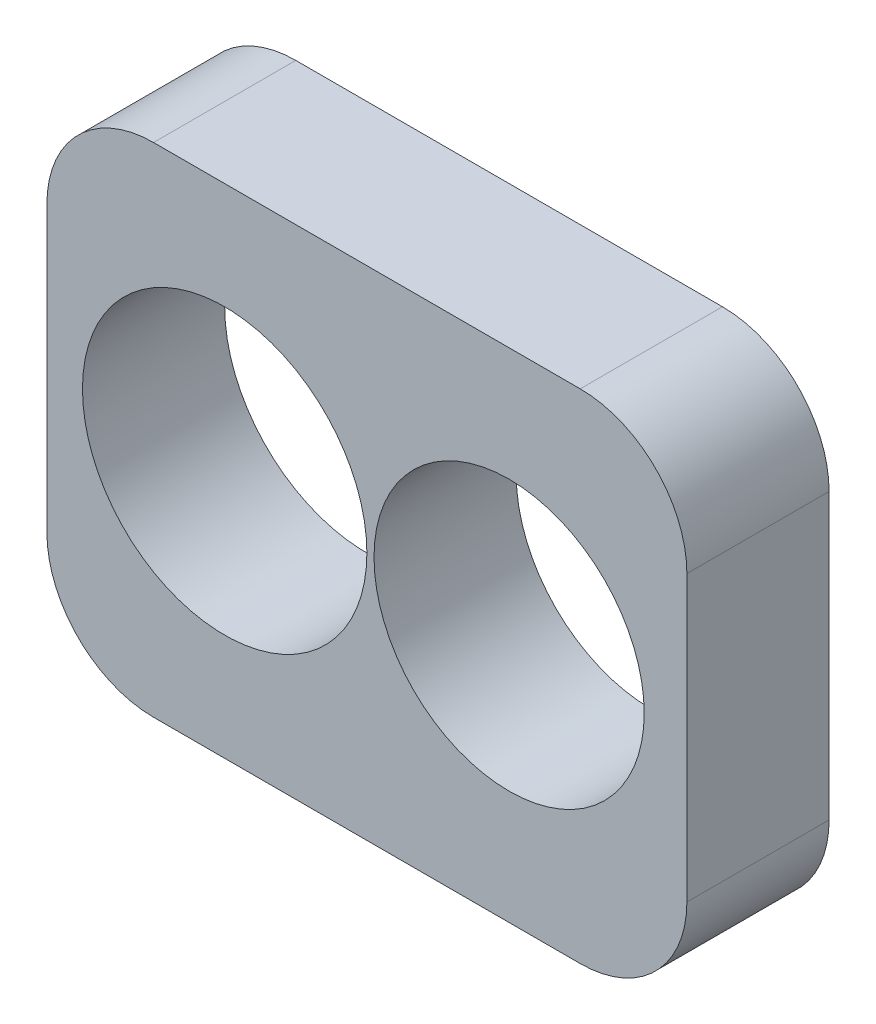
from build123d import *

# Parameters (mm, degrees)
BOSS_EXTRUDE1_DEPTH     = 20
SKETCH3_R               = 20
CUT_EXTRUDE2_DEPTH      = 1
CUT_EXTRUDE2_DEPTH_BACK = 21
SKETCH4_R               = 19
CUT_EXTRUDE3_DEPTH      = 21


with BuildPart() as part:
    # Sketch1 → Boss-Extrude1 (new body)
    with BuildSketch(Plane.XY):
        with BuildLine():
            Line((30, -35), (-30, -35))
            ThreePointArc((-30, -35), (-40.606601718, -30.606601718), (-45, -20))
            Line((-45, -20), (-45, 20))
            ThreePointArc((-45, 20), (-40.606601718, 30.606601718), (-30, 35))
            Line((-30, 35), (30, 35))
            ThreePointArc((30, 35), (40.606601718, 30.606601718), (45, 20))
            Line((45, 20), (45, -20))
            ThreePointArc((45, -20), (40.606601718, -30.606601718), (30, -35))
        make_face()
    extrude(amount=BOSS_EXTRUDE1_DEPTH)

    # Sketch3 → Cut-Extrude2 (cut, two sides)
    with BuildSketch(Plane.XY.offset(20)) as cut_extrude2_sk:
        with Locations((-20, 0)):
            Circle(SKETCH3_R)
    extrude(amount=CUT_EXTRUDE2_DEPTH, mode=Mode.SUBTRACT)
    extrude(cut_extrude2_sk.sketch, amount=-CUT_EXTRUDE2_DEPTH_BACK, mode=Mode.SUBTRACT)

    # Sketch4 → Cut-Extrude3 (cut, through all)
    with BuildSketch(Plane.XY.offset(20)):
        with Locations((20, 0)):
            Circle(SKETCH4_R)
    extrude(amount=-CUT_EXTRUDE3_DEPTH, mode=Mode.SUBTRACT)


solid = part.part
